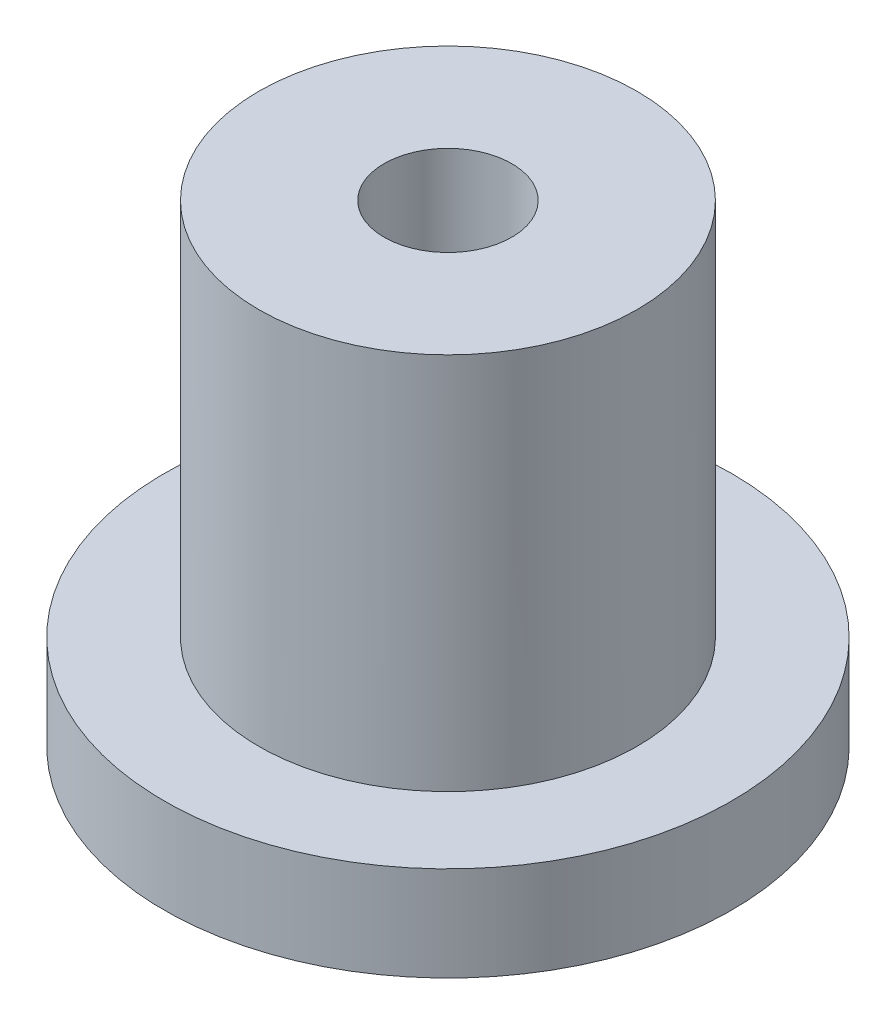
from build123d import *

# Parameters (mm, degrees)
SKETCH_1_R          = 4
EXTRUDE_1_DEPTH     = 8
SKETCH_3_R          = 6
EXTRUDE_2_DEPTH     = 2
SKETCH_2_R          = 1.35
CUT_EXTRUDE_1_DEPTH = 12


with BuildPart() as part:
    # 스케치1 → 보스-돌출1 (new body)
    with BuildSketch(Plane(origin=(0, 0, 0), x_dir=(1, 0, 0), z_dir=(0, 1, 0))):
        Circle(SKETCH_1_R)
    extrude(amount=EXTRUDE_1_DEPTH)

    # 스케치3 → 보스-돌출2 (add)
    with BuildSketch(Plane.XZ):
        Circle(SKETCH_3_R)
    extrude(amount=EXTRUDE_2_DEPTH)

    # 스케치2 → 컷-돌출1 (cut)
    with BuildSketch(Plane(origin=(0, 8, 0), x_dir=(1, 0, 0), z_dir=(0, 1, 0))):
        Circle(SKETCH_2_R)
    extrude(amount=-CUT_EXTRUDE_1_DEPTH, mode=Mode.SUBTRACT)


solid = part.part
